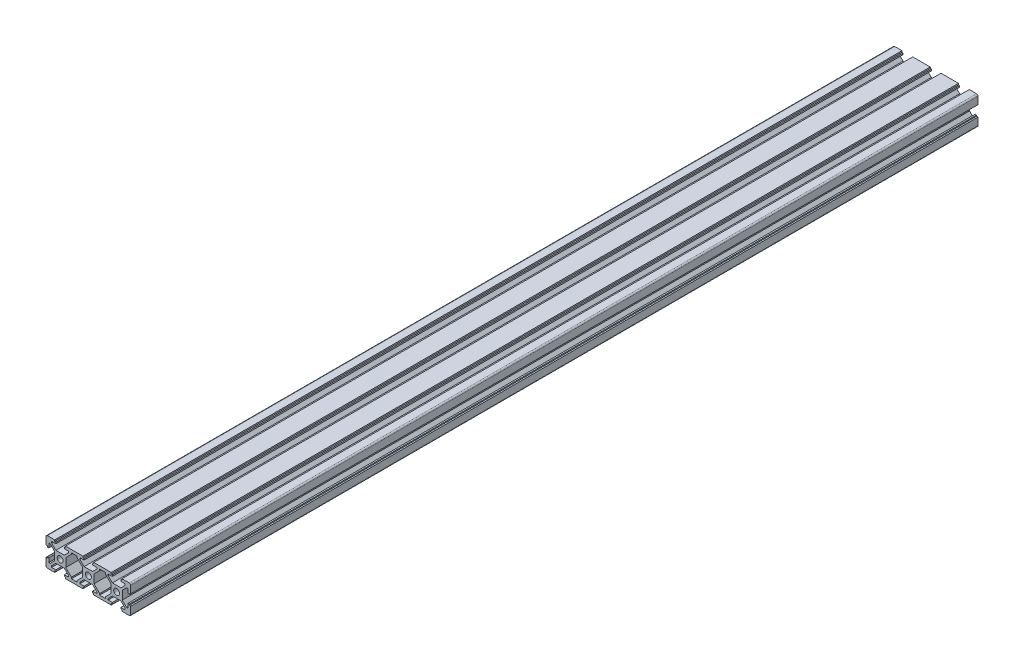
from build123d import *

# Parameters (mm, degrees)
SKETCH_1_R      = 2.103037388
EXTRUDE_1_DEPTH = 600


with BuildPart() as part:
    # 草图1 → 凸台-拉伸1 (new body)
    with BuildSketch(Plane.XY):
        with BuildLine():
            Line((-32.248557314, -0.229845073), (-32.248557314, -1.030984477))
            Line((-32.248557314, -1.030984477), (-33.250003689, -1.030984477))
            Line((-33.250003689, -1.030984477), (-33.250003689, -6.238394755))
            ThreePointArc((-33.250003689, -6.238394755), (-32.949991565, -6.938952391), (-32.24382973, -7.225524788))
            Line((-32.24382973, -7.225524788), (-27.078556151, -7.225524788))
            Line((-27.078556151, -7.225524788), (-27.078556151, -6.224078413))
            Line((-27.078556151, -6.224078413), (-26.277399051, -6.224078413))
            Line((-26.277399051, -6.224078413), (-26.277399051, -5.212715786))
            Line((-26.277399051, -5.212715786), (-29.27300496, -5.212715786))
            Line((-29.27300496, -5.212715786), (-29.27300496, -4.211495229))
            Line((-29.27300496, -4.211495229), (-26.279632969, -1.225390538))
            Line((-26.279632969, -1.225390538), (-20.24902045, -1.225390538))
            Line((-20.24902045, -1.225390538), (-17.255648459, -4.211495229))
            Line((-17.255648459, -4.211495229), (-17.255648459, -5.212715786))
            Line((-17.255648459, -5.212715786), (-20.251254368, -5.212715786))
            Line((-20.251254368, -5.212715786), (-20.251254368, -6.224078413))
            Line((-20.251254368, -6.224078413), (-19.450097268, -6.224078413))
            Line((-19.450097268, -6.224078413), (-19.450097268, -7.225524788))
            Line((-19.450097268, -7.225524788), (-7.064233131, -7.225524788))
            Line((-7.064233131, -7.225524788), (-7.064233131, -6.224078413))
            Line((-7.064233131, -6.224078413), (-6.263076031, -6.224078413))
            Line((-6.263076031, -6.224078413), (-6.263076031, -5.212715786))
            Line((-6.263076031, -5.212715786), (-9.25868194, -5.212715786))
            Line((-9.25868194, -5.212715786), (-9.25868194, -4.211495229))
            Line((-9.25868194, -4.211495229), (-6.265309949, -1.225390538))
            Line((-6.265309949, -1.225390538), (-0.234697429, -1.225390538))
            Line((-0.234697429, -1.225390538), (2.758674561, -4.211495229))
            Line((2.758674561, -4.211495229), (2.758674561, -5.212715786))
            Line((2.758674561, -5.212715786), (-0.236931348, -5.212715786))
            Line((-0.236931348, -5.212715786), (-0.236931348, -6.224078413))
            Line((-0.236931348, -6.224078413), (0.564225752, -6.224078413))
            Line((0.564225752, -6.224078413), (0.564225752, -7.225524788))
            Line((0.564225752, -7.225524788), (12.945482254, -7.225524788))
            Line((12.945482254, -7.225524788), (12.945482254, -6.219120287))
            Line((12.945482254, -6.219120287), (13.751246989, -6.219120287))
            Line((13.751246989, -6.219120287), (13.751246989, -5.212715786))
            Line((13.751246989, -5.212715786), (10.755641081, -5.212715786))
            Line((10.755641081, -5.212715786), (10.755641081, -4.211495229))
            Line((10.755641081, -4.211495229), (13.749013071, -1.225390538))
            Line((13.749013071, -1.225390538), (19.779625591, -1.225390538))
            Line((19.779625591, -1.225390538), (22.772997581, -4.211495229))
            Line((22.772997581, -4.211495229), (22.772997581, -5.212715786))
            Line((22.772997581, -5.212715786), (19.772784037, -5.212715786))
            Line((19.772784037, -5.212715786), (19.772784037, -6.219120287))
            Line((19.772784037, -6.219120287), (20.573941137, -6.219120287))
            Line((20.573941137, -6.219120287), (20.573941137, -7.225524788))
            Line((20.573941137, -7.225524788), (25.743822351, -7.225524788))
            ThreePointArc((25.743822351, -7.225524788), (26.449984187, -6.938952391), (26.749996311, -6.238394755))
            Line((26.749996311, -6.238394755), (26.749996311, -1.030984477))
            Line((26.749996311, -1.030984477), (25.748549936, -1.030984477))
            Line((25.748549936, -1.030984477), (25.748549936, -0.229827377))
            Line((25.748549936, -0.229827377), (24.761302481, -0.229827377))
            Line((24.761302481, -0.229827377), (24.761302481, -3.234203038))
            Line((24.761302481, -3.234203038), (23.759856106, -3.234203038))
            Line((23.759856106, -3.234203038), (20.770104831, -0.237175589))
            Line((20.770104831, -0.237175589), (20.770104831, 5.786126014))
            Line((20.770104831, 5.786126014), (23.759856106, 8.783153462))
            Line((23.759856106, 8.783153462), (24.761302481, 8.783153462))
            Line((24.761302481, 8.783153462), (24.761302481, 5.778777801))
            Line((24.761302481, 5.778777801), (25.748549936, 5.778777801))
            Line((25.748549936, 5.778777801), (25.748549936, 6.579934901))
            Line((25.748549936, 6.579934901), (26.749996311, 6.579934901))
            Line((26.749996311, 6.579934901), (26.749996311, 11.768212512))
            ThreePointArc((26.749996311, 11.768212512), (26.456722319, 12.481138347), (25.743822351, 12.774475212))
            Line((25.743822351, 12.774475212), (20.573941137, 12.774475212))
            Line((20.573941137, 12.774475212), (20.573941137, 11.768070711))
            Line((20.573941137, 11.768070711), (19.772784037, 11.768070711))
            Line((19.772784037, 11.768070711), (19.772784037, 10.761666211))
            Line((19.772784037, 10.761666211), (22.772997581, 10.761666211))
            Line((22.772997581, 10.761666211), (22.772997581, 9.760445653))
            Line((22.772997581, 9.760445653), (19.779625591, 6.774340962))
            Line((19.779625591, 6.774340962), (13.749013071, 6.774340962))
            Line((13.749013071, 6.774340962), (10.755641081, 9.760445653))
            Line((10.755641081, 9.760445653), (10.755641081, 10.761666211))
            Line((10.755641081, 10.761666211), (13.746639354, 10.761666211))
            Line((13.746639354, 10.761666211), (13.746639354, 11.768070711))
            Line((13.746639354, 11.768070711), (12.945482254, 11.768070711))
            Line((12.945482254, 11.768070711), (12.945482254, 12.774475212))
            Line((12.945482254, 12.774475212), (0.564225752, 12.774475212))
            Line((0.564225752, 12.774475212), (0.564225752, 11.773028837))
            Line((0.564225752, 11.773028837), (-0.236931348, 11.773028837))
            Line((-0.236931348, 11.773028837), (-0.236931348, 10.761666211))
            Line((-0.236931348, 10.761666211), (2.758674561, 10.761666211))
            Line((2.758674561, 10.761666211), (2.758674561, 9.760445653))
            Line((2.758674561, 9.760445653), (-0.234697429, 6.774340962))
            Line((-0.234697429, 6.774340962), (-6.265309949, 6.774340962))
            Line((-6.265309949, 6.774340962), (-9.25868194, 9.760445653))
            Line((-9.25868194, 9.760445653), (-9.25868194, 10.761666211))
            Line((-9.25868194, 10.761666211), (-6.263076031, 10.761666211))
            Line((-6.263076031, 10.761666211), (-6.263076031, 11.773028837))
            Line((-6.263076031, 11.773028837), (-7.064233131, 11.773028837))
            Line((-7.064233131, 11.773028837), (-7.064233131, 12.774475212))
            Line((-7.064233131, 12.774475212), (-19.450097268, 12.774475212))
            Line((-19.450097268, 12.774475212), (-19.450097268, 11.773028837))
            Line((-19.450097268, 11.773028837), (-20.251254368, 11.773028837))
            Line((-20.251254368, 11.773028837), (-20.251254368, 10.761666211))
            Line((-20.251254368, 10.761666211), (-17.255648459, 10.761666211))
            Line((-17.255648459, 10.761666211), (-17.255648459, 9.760445653))
            Line((-17.255648459, 9.760445653), (-20.24902045, 6.774340962))
            Line((-20.24902045, 6.774340962), (-26.279632969, 6.774340962))
            Line((-26.279632969, 6.774340962), (-29.27300496, 9.760445653))
            Line((-29.27300496, 9.760445653), (-29.27300496, 10.761666211))
            Line((-29.27300496, 10.761666211), (-26.277399051, 10.761666211))
            Line((-26.277399051, 10.761666211), (-26.277399051, 11.773028837))
            Line((-26.277399051, 11.773028837), (-27.078556151, 11.773028837))
            Line((-27.078556151, 11.773028837), (-27.078556151, 12.774475212))
            Line((-27.078556151, 12.774475212), (-32.24382973, 12.774475212))
            ThreePointArc((-32.24382973, 12.774475212), (-32.956729698, 12.481138347), (-33.250003689, 11.768212512))
            Line((-33.250003689, 11.768212512), (-33.250003689, 6.560802234))
            Line((-33.250003689, 6.560802234), (-32.248557314, 6.560802234))
            Line((-32.248557314, 6.560802234), (-32.248557314, 5.759645134))
            Line((-32.248557314, 5.759645134), (-31.261309859, 5.759645134))
            Line((-31.261309859, 5.759645134), (-31.261309859, 8.764020795))
            Line((-31.261309859, 8.764020795), (-30.259863484, 8.764020795))
            Line((-30.259863484, 8.764020795), (-27.27011221, 5.766993347))
            Line((-27.27011221, 5.766993347), (-27.27011221, -0.237175589))
            Line((-27.27011221, -0.237175589), (-30.259863484, -3.234203038))
            Line((-30.259863484, -3.234203038), (-31.261309859, -3.234203038))
            Line((-31.261309859, -3.234203038), (-31.261309859, -0.229845073))
            Line((-31.261309859, -0.229845073), (-32.248557314, -0.229845073))
        make_face()
        with Locations((-3.250003689, 2.774475212)):
            Circle(SKETCH_1_R, mode=Mode.SUBTRACT)
        with Locations((-23.250003689, 2.774475212)):
            Circle(SKETCH_1_R, mode=Mode.SUBTRACT)
        with Locations((16.749996311, 2.774475212)):
            Circle(SKETCH_1_R, mode=Mode.SUBTRACT)
        Polygon((-19.258541209, 5.786126014), (-19.258541209, -0.237175589), (-15.26734356, -4.238086639), (-15.26734356, -5.22228212), (-11.246986839, -5.22228212), (-11.246986839, -4.238086639), (-7.25578919, -0.237175589), (-7.25578919, 2.774475212), (-7.25578919, 5.786126014), (-11.246986839, 9.787037063), (-11.246986839, 10.771232544), (-15.26734356, 10.771232544), (-15.26734356, 9.787037063), align=None, mode=Mode.SUBTRACT)
        Polygon((4.74697946, -5.22228212), (8.767336181, -5.22228212), (8.767336181, -4.238086639), (12.758533831, -0.237175589), (12.758533831, 2.774475212), (12.758533831, 5.786126014), (8.767336181, 9.787037063), (8.767336181, 10.771232544), (4.74697946, 10.771232544), (4.74697946, 9.787037063), (0.755781811, 5.786126014), (0.755781811, 2.774475212), (0.755781811, -0.237175589), (4.74697946, -4.238086639), align=None, mode=Mode.SUBTRACT)
    extrude(amount=EXTRUDE_1_DEPTH)


solid = part.part
